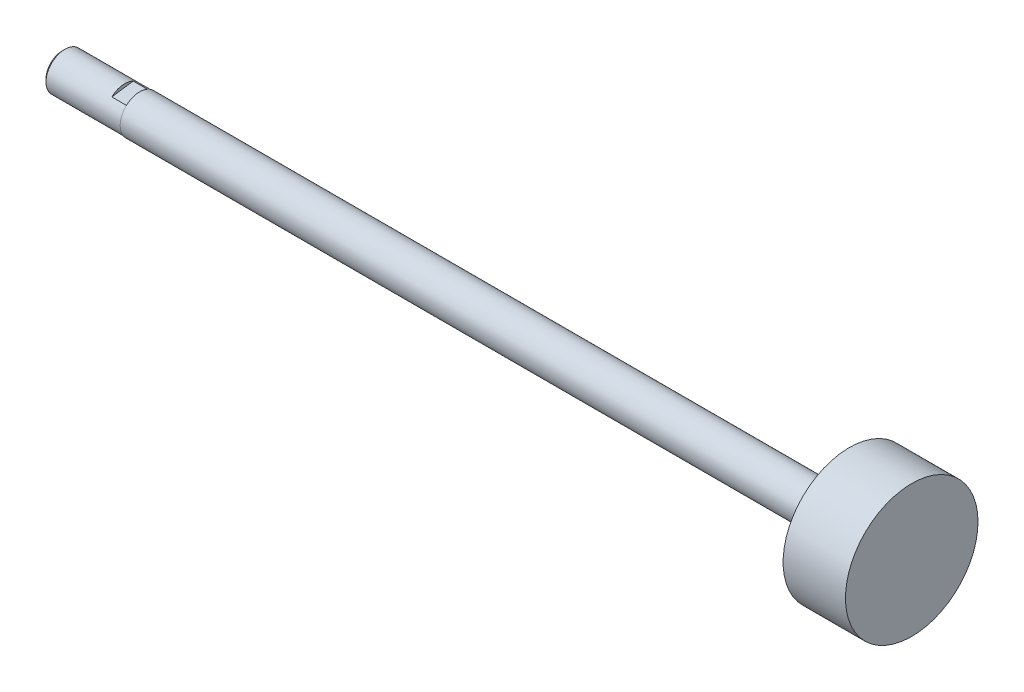
from build123d import *

# Parameters (mm, degrees)
SKETCH1_W           = 12.7
SKETCH1_H           = 3.86334
BOSS_EXTRUDE1_DEPTH = 3.048
SKETCH3_R           = 3.9624
BOSS_EXTRUDE2_DEPTH = 144.526
SKETCH4_R           = 13.49375
BOSS_EXTRUDE3_DEPTH = 12.7
CHAMFER1_SIZE       = 0.53594


with BuildPart() as part:
    # Sketch1 → Revolve1 (revolve)
    with BuildSketch(Plane.XY):
        with Locations((739.199890203, 1.93167)):
            Rectangle(SKETCH1_W, SKETCH1_H)
    revolve(axis=Axis((732.849890203, 0, 0), (1, 0, 0)))

    # Sketch2 → Boss-Extrude1 (add)
    with BuildSketch(Plane(origin=(745.549890203, 0, 0), x_dir=(0, 0, -1), z_dir=(1, 0, 0))):
        with BuildLine():
            Line((2.623507611, -2.835948478), (-1.73539242, -3.451638611))
            ThreePointArc((-1.73539242, -3.451638611), (-3.825367985, -0.540329282), (-2.623507611, 2.835948478))
            Line((-2.623507611, 2.835948478), (1.73539242, 3.451638611))
            ThreePointArc((1.73539242, 3.451638611), (3.825367985, 0.540329282), (2.623507611, -2.835948478))
        make_face()
    extrude(amount=BOSS_EXTRUDE1_DEPTH)

    # Sketch3 → Boss-Extrude2 (add)
    with BuildSketch(Plane(origin=(748.597890203, 0, 0), x_dir=(0, -1, 0), z_dir=(-1, 0, 0))):
        Circle(SKETCH3_R)
    extrude(amount=-BOSS_EXTRUDE2_DEPTH)

    # Sketch4 → Boss-Extrude3 (add)
    with BuildSketch(Plane(origin=(893.123890203, 0, 0), x_dir=(0, -1, 0), z_dir=(-1, 0, 0))):
        Circle(SKETCH4_R)
    extrude(amount=-BOSS_EXTRUDE3_DEPTH)

    # Chamfer1
    chamfer1_edges = [part.edges().sort_by_distance(p)[0] for p in [
        (732.849890203, -3.86334, 0),
    ]]
    chamfer(chamfer1_edges, length=CHAMFER1_SIZE)


solid = part.part
